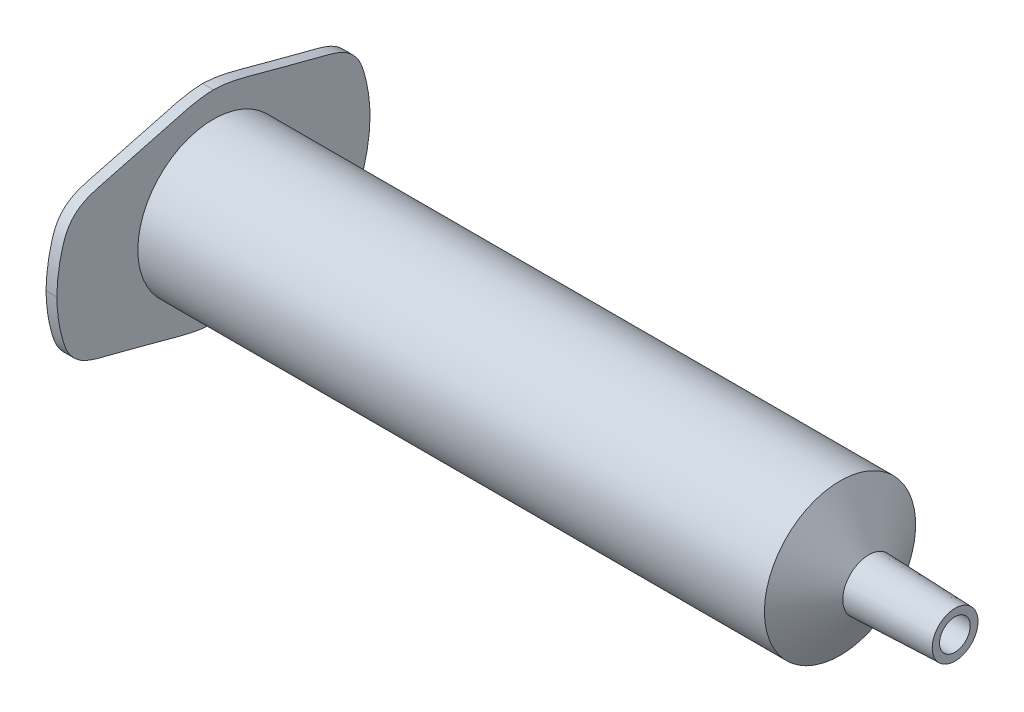
from build123d import *

# Parameters (mm, degrees)
SKETCH_2_R      = 6.3
EXTRUDE_1_DEPTH = 1


with BuildPart() as part:
    # Эскиз1 → Повернуть-Тонкостенный3 (revolve)
    with BuildSketch(Plane.XY):
        Polygon((-41.34237999, 7), (16.65762001, 7), (19.313431248, 2.4), (27.313431248, 2.120633844), (27.2890016, 1.421060265), (18.901221633, 1.713967996), (16.253474821, 6.3), (-41.34237999, 6.3), align=None)
    revolve(axis=Axis((-11.565290599, 0, 0), (1, 0, 0)))

    # Эскиз2 → Бобышка-Вытянуть1 (add)
    with BuildSketch(Plane.ZY.offset(41.34237999)):
        with BuildLine():
            add(Edge.make_bspline(
                [(-14.5, 0), (-14.474728727, -1.250629482), (-14.242328004, -3.018058456), (-13.480726208, -5.156192857), (-12.386888331, -6.242148201), (-11.142838362, -6.727444369), (-9.562420274, -7.125179123), (-7.483693891, -7.691921698), (-4.724391308, -8.363720089), (-2.266989559, -9.122366404), (-0.655182959, -9.33281469), (-0.082845288, -9.355711433), (-2e-08, -9.357888542)],
                knots=[0, 0, 0, 0, 0.178779937, 0.255445115, 0.319697761, 0.392573489, 0.443879083, 0.553726464, 0.701162756, 0.851190942, 0.921407161, 0.933286403, 0.933286403, 0.933286403, 0.933286403], degree=3))
            add(Edge.make_bspline(
                [(14.5, 0), (14.474728734, -1.250629483), (14.242328006, -3.018058455), (13.480726218, -5.156192862), (12.386888336, -6.242148209), (11.142838364, -6.727444374), (9.562420275, -7.125179117), (7.483693885, -7.691921727), (4.724391348, -8.363719948), (2.266989446, -9.122366813), (0.655183079, -9.332814217), (0.082845248, -9.355711433), (-2e-08, -9.357888542)],
                knots=[0, 0, 0, 0, 0.178779937, 0.255445115, 0.319697761, 0.392573489, 0.443879083, 0.553726464, 0.701162756, 0.851190942, 0.921407161, 0.933286403, 0.933286403, 0.933286403, 0.933286403], degree=3))
            add(Edge.make_bspline(
                [(14.5, 0), (14.474728734, 1.250629483), (14.242328006, 3.018058455), (13.480726218, 5.156192862), (12.386888336, 6.242148209), (11.142838364, 6.727444374), (9.562420275, 7.125179117), (7.483693885, 7.691921727), (4.724391348, 8.363719948), (2.266989446, 9.122366813), (0.655183079, 9.332814217), (0.082845248, 9.355711433), (-2e-08, 9.357888542)],
                knots=[0, 0, 0, 0, 0.178779937, 0.255445115, 0.319697761, 0.392573489, 0.443879083, 0.553726464, 0.701162756, 0.851190942, 0.921407161, 0.933286403, 0.933286403, 0.933286403, 0.933286403], degree=3))
            add(Edge.make_bspline(
                [(-14.5, 0), (-14.474728727, 1.250629482), (-14.242328004, 3.018058456), (-13.480726208, 5.156192857), (-12.386888331, 6.242148201), (-11.142838362, 6.727444369), (-9.562420274, 7.125179123), (-7.483693891, 7.691921698), (-4.724391308, 8.363720089), (-2.266989559, 9.122366404), (-0.655182959, 9.33281469), (-0.082845288, 9.355711433), (-2e-08, 9.357888542)],
                knots=[0, 0, 0, 0, 0.178779937, 0.255445115, 0.319697761, 0.392573489, 0.443879083, 0.553726464, 0.701162756, 0.851190942, 0.921407161, 0.933286403, 0.933286403, 0.933286403, 0.933286403], degree=3))
        make_face()
        Circle(SKETCH_2_R, mode=Mode.SUBTRACT)
    extrude(amount=EXTRUDE_1_DEPTH)


solid = part.part
